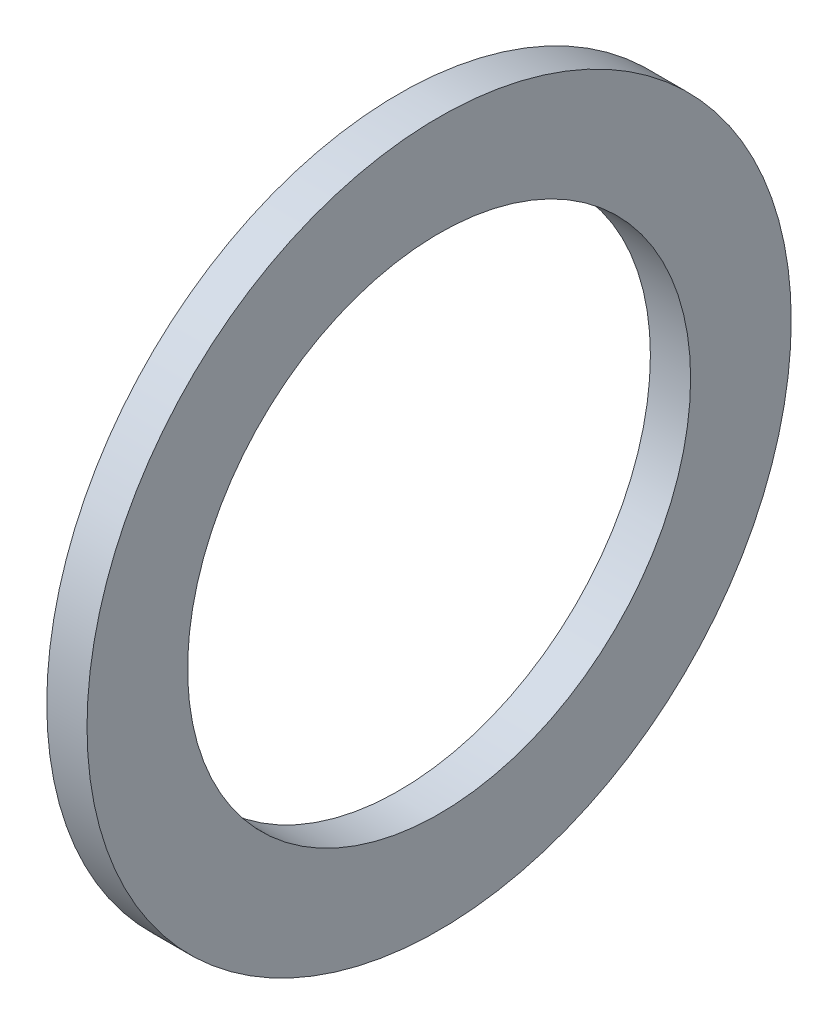
from build123d import *

# Parameters (mm, degrees)
SZKIC1_R                    = 17.5
SZKIC1_R_2                  = 12.5
DODANIE_WYCI_GNI_CIE1_DEPTH = 2


with BuildPart() as part:
    # Szkic1 → Dodanie-wyciągnięcie1 (new body)
    with BuildSketch(Plane(origin=(0, 0, 0), x_dir=(0, 0, -1), z_dir=(1, 0, 0))):
        Circle(SZKIC1_R)
        Circle(SZKIC1_R_2, mode=Mode.SUBTRACT)
    extrude(amount=DODANIE_WYCI_GNI_CIE1_DEPTH)


solid = part.part
